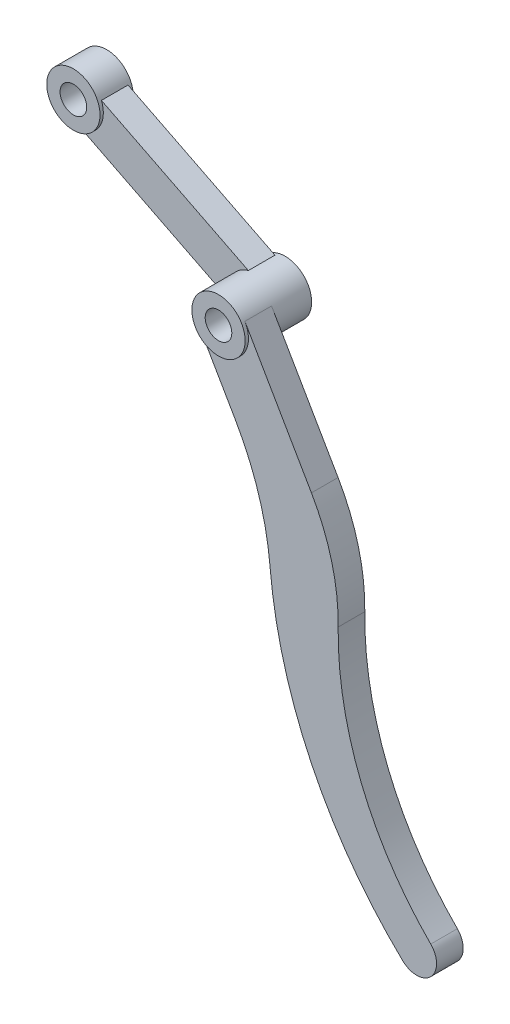
from build123d import *

# Parameters (mm, degrees)
SKETCH_1_R        = 8
SKETCH_1_R_2      = 4
EXTRUDE_1_DEPTH   = 10
EXTRUDE_1_2_DEPTH = 10
EXTRUDE_START     = -1
EXTRUDE_2_DEPTH   = 8
EXTRUDE_START_2   = 1
EXTRUDE_3_DEPTH   = 8
SKETCH_5_R        = 8
SKETCH_5_R_2      = 4
EXTRUDE_4_DEPTH   = 10


with BuildPart() as part:
    # 草图1 → 凸台-拉伸1 (new body)
    with BuildSketch(Plane.XY):
        Circle(SKETCH_1_R)
        Circle(SKETCH_1_R_2, mode=Mode.SUBTRACT)
    extrude(amount=-EXTRUDE_1_DEPTH)



with BuildPart() as body_2:
    # 草图1 → Extrude 1 2 (new body)
    with BuildSketch(Plane.XY):
        with Locations((-53.605968084, 26.951812291)):
            Circle(SKETCH_1_R)
        with Locations((-53.605968084, 26.951812291)):
            Circle(SKETCH_1_R_2, mode=Mode.SUBTRACT)
    extrude(amount=-EXTRUDE_1_2_DEPTH)


with BuildPart() as part_1:
    add(part.part)

    add(body_2.part)  # 凸台-拉伸2 merges body 2
    # 草图3 → 凸台-拉伸2 (add)
    with BuildSketch(Plane.XY.offset(EXTRUDE_START)):
        with BuildLine():
            Line((-51.573547302, 19.214289059), (-7.42278324, -2.983670385))
            ThreePointArc((-7.42278324, -2.983670385), (-7.147462411, 3.593574972), (-2.032420782, 7.737523232))
            Line((-2.032420782, 7.737523232), (-46.183184844, 29.935482676))
            ThreePointArc((-46.183184844, 29.935482676), (-46.458505673, 23.358237319), (-51.573547302, 19.214289059))
        make_face()
    extrude(amount=-EXTRUDE_2_DEPTH)



with BuildPart() as body_2_2:
    # 草图4 → 凸台-拉伸3 (new body)
    with BuildSketch(Plane.XY.offset(EXTRUDE_START_2)):
        with BuildLine():
            Line((6.92820323, 4), (26.92820323, -30.641016151))
            ThreePointArc((26.92820323, -30.641016151), (33.036798625, -45.545943872), (34.959960983, -61.538856509))
            ThreePointArc((34.959960983, -61.538856509), (41.911210079, -98.657642521), (62.774179905, -130.135581289))
            ThreePointArc((62.774179905, -130.135581289), (62.827441336, -138.566924041), (54.397444356, -138.726699833))
            ThreePointArc((54.397444356, -138.726699833), (26.885397662, -101.001387411), (14.477282647, -55.988604867))
            ThreePointArc((14.477282647, -55.988604867), (11.073298234, -38.952300047), (4.07179677, -23.052558883))
            Line((4.07179677, -23.052558883), (-6.92820323, -4))
            ThreePointArc((-6.92820323, -4), (4, -6.92820323), (6.92820323, 4))
        make_face()
    extrude(amount=EXTRUDE_3_DEPTH)


with BuildPart() as part_2:
    add(part_1.part)

    add(body_2_2.part)  # 凸台-拉伸4 merges body 2 2
    # 草图5 → 凸台-拉伸4 (add)
    with BuildSketch(Plane.XY):
        Circle(SKETCH_5_R)
        Circle(SKETCH_5_R_2, mode=Mode.SUBTRACT)
    extrude(amount=EXTRUDE_4_DEPTH)


solid = part_2.part
